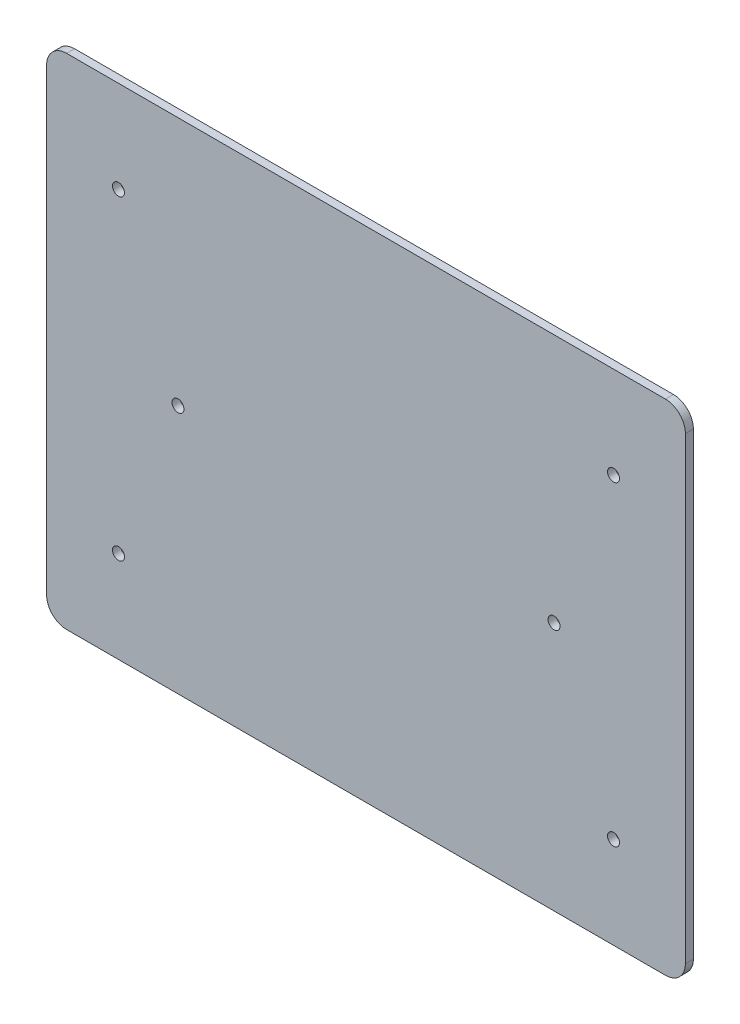
from build123d import *

# Parameters (mm, degrees)
RESSALTO_EXTRUS_O1_DEPTH = 2
ESBO_O2_R                = 1.5
CORTE_EXTRUS_O1_DEPTH    = 10


with BuildPart() as part:
    # Esboço1 → Ressalto-extrusão1 (new body)
    with BuildSketch(Plane.XY):
        with BuildLine():
            Line((47.367635672, -148.027068541), (-102.632364328, -148.027068541))
            ThreePointArc((-102.632364328, -148.027068541), (-106.167898234, -146.562602447), (-107.632364328, -143.027068541))
            Line((-107.632364328, -143.027068541), (-107.632364328, -28.027068541))
            ThreePointArc((-107.632364328, -28.027068541), (-106.167898234, -24.491534635), (-102.632364328, -23.027068541))
            Line((-102.632364328, -23.027068541), (47.367635672, -23.027068541))
            ThreePointArc((47.367635672, -23.027068541), (50.903169578, -24.491534635), (52.367635672, -28.027068541))
            Line((52.367635672, -28.027068541), (52.367635672, -143.027068541))
            ThreePointArc((52.367635672, -143.027068541), (50.903169578, -146.562602447), (47.367635672, -148.027068541))
        make_face()
    extrude(amount=RESSALTO_EXTRUS_O1_DEPTH)

    # Esboço2 → Corte-extrusão1 (cut)
    with BuildSketch(Plane(origin=(0, 0, 0), x_dir=(-1, 0, 0), z_dir=(0, 0, -1))):
        with Locations((-34.367635672, -125.027068541)):
            Circle(ESBO_O2_R)
        with Locations((-19.467635672, -85.527068541)):
            Circle(ESBO_O2_R)
        with Locations((-34.367635672, -46.027068541)):
            Circle(ESBO_O2_R)
        with Locations((89.632364328, -46.027068541)):
            Circle(ESBO_O2_R)
        with Locations((74.732364328, -85.527068541)):
            Circle(ESBO_O2_R)
        with Locations((89.632364328, -125.027068541)):
            Circle(ESBO_O2_R)
    extrude(amount=-CORTE_EXTRUS_O1_DEPTH, mode=Mode.SUBTRACT)


solid = part.part
